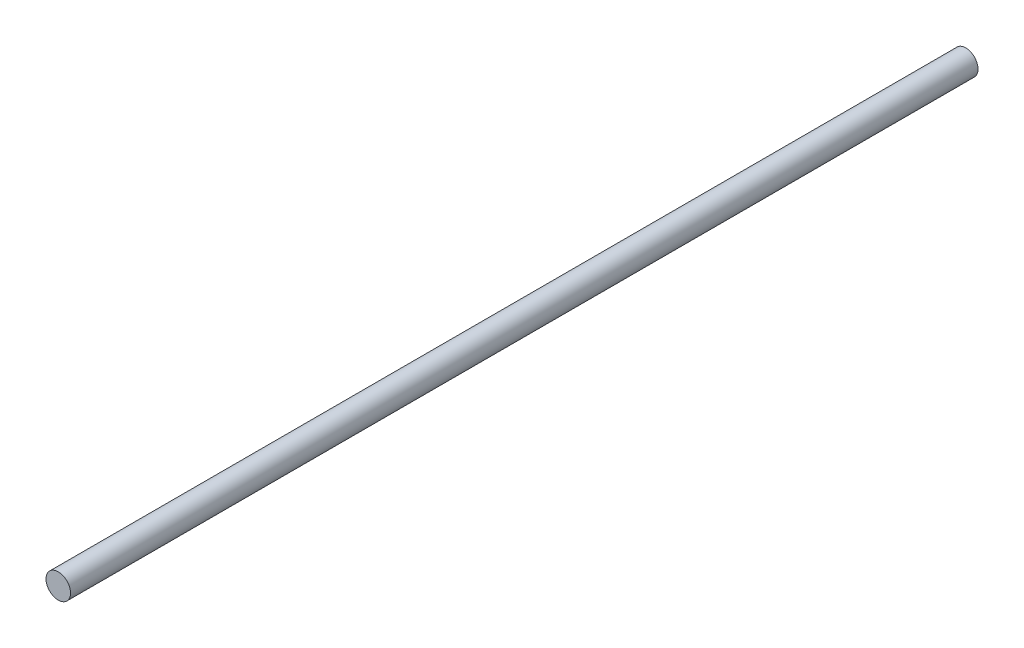
from build123d import *

# Parameters (mm, degrees)
SKETCH1_R           = 4
BOSS_EXTRUDE1_DEPTH = 287.5
SKETCH2_R           = 4
BOSS_EXTRUDE2_DEPTH = 45
SKETCH3_R           = 4
CUT_EXTRUDE1_DEPTH  = 105
SKETCH4_R           = 4
BOSS_EXTRUDE3_DEPTH = 68.5


with BuildPart() as part:
    # Sketch1 → Boss-Extrude1 (new body)
    with BuildSketch(Plane.XY):
        Circle(SKETCH1_R)
    extrude(amount=BOSS_EXTRUDE1_DEPTH)

    # Sketch2 → Boss-Extrude2 (add)
    with BuildSketch(Plane.XY.offset(287.5)):
        Circle(SKETCH2_R)
    extrude(amount=BOSS_EXTRUDE2_DEPTH)

    # Sketch3 → Cut-Extrude1 (cut)
    with BuildSketch(Plane(origin=(0, 0, 0), x_dir=(-1, 0, 0), z_dir=(0, 0, -1))):
        Circle(SKETCH3_R)
    extrude(amount=-CUT_EXTRUDE1_DEPTH, mode=Mode.SUBTRACT)

    # Sketch4 → Boss-Extrude3 (add)
    with BuildSketch(Plane(origin=(0, 0, 105), x_dir=(-1, 0, 0), z_dir=(0, 0, -1))):
        Circle(SKETCH4_R)
    extrude(amount=BOSS_EXTRUDE3_DEPTH)


solid = part.part
